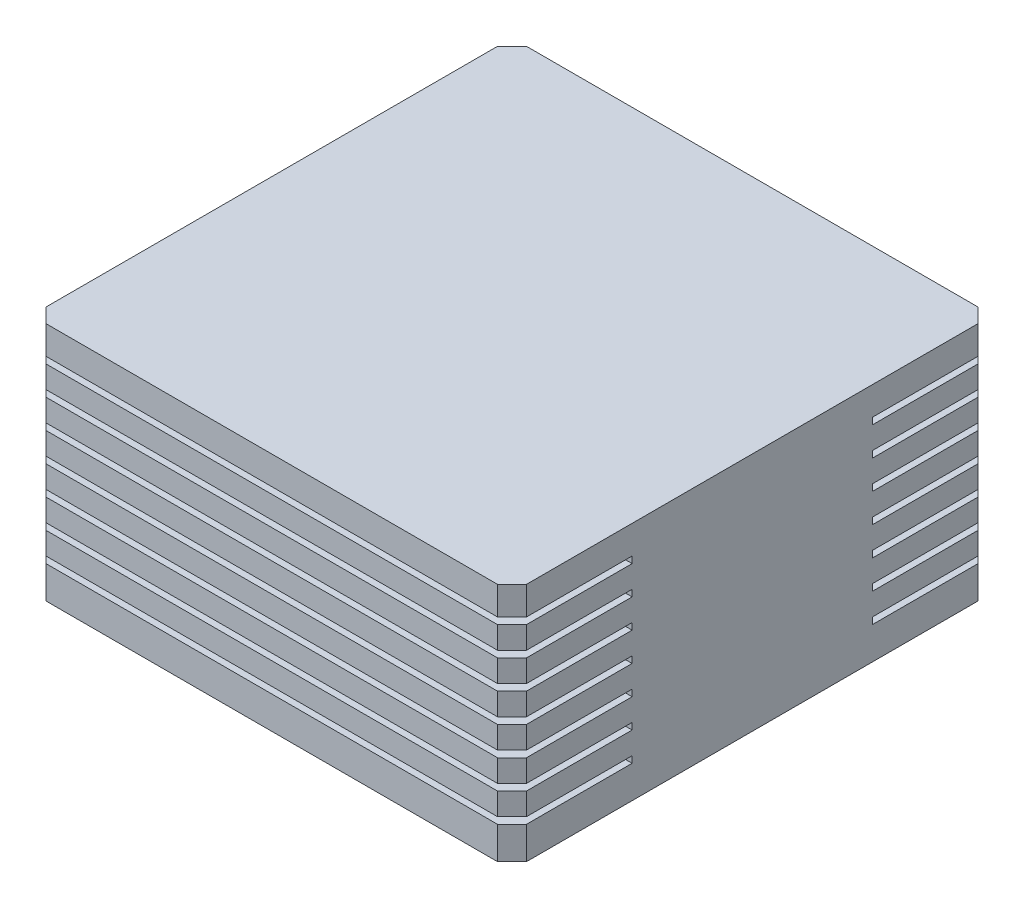
from build123d import *

# Parameters (mm, degrees)
SKETCH1_W           = 100
SKETCH1_H           = 100
BOSS_EXTRUDE1_DEPTH = 50
CHAMFER1_SIZE       = 3
SKETCH3_W           = 100
SKETCH3_H           = 1.369103339
CUT_EXTRUDE1_DEPTH  = 25
SKETCH4_W           = 72
SKETCH4_H           = 1.369103339
SKETCH4_W_2         = 3
SKETCH4_W_3         = 75
CUT_EXTRUDE2_DEPTH  = 25
SKETCH5_W           = 75
SKETCH5_H           = 1.369103339
CUT_EXTRUDE3_DEPTH  = 25


with BuildPart() as part:
    # Sketch1 → Boss-Extrude1 (new body)
    with BuildSketch(Plane(origin=(0, 0, 0), x_dir=(1, 0, 0), z_dir=(0, 1, 0))):
        with Locations((50, -50)):
            Rectangle(SKETCH1_W, SKETCH1_H)
    extrude(amount=BOSS_EXTRUDE1_DEPTH)

    # Chamfer1
    chamfer1_edges = [part.edges().sort_by_distance(p)[0] for p in [
        (0, 25, 0),
        (100, 25, 0),
        (100, 25, 100),
        (0, 25, 100),
    ]]
    chamfer(chamfer1_edges, length=CHAMFER1_SIZE)

    # Sketch3 → Cut-Extrude1 (cut)
    with BuildSketch(Plane.ZY):
        with Locations((50, 43.425849107)):
            Rectangle(SKETCH3_W, SKETCH3_H)
        with Locations((50, 37.425849107)):
            Rectangle(SKETCH3_W, SKETCH3_H)
        with Locations((50, 31.425849107)):
            Rectangle(SKETCH3_W, SKETCH3_H)
        with Locations((50, 25.425849107)):
            Rectangle(SKETCH3_W, SKETCH3_H)
        with Locations((50, 19.425849107)):
            Rectangle(SKETCH3_W, SKETCH3_H)
        with Locations((50, 13.425849107)):
            Rectangle(SKETCH3_W, SKETCH3_H)
        with Locations((50, 7.425849108)):
            Rectangle(SKETCH3_W, SKETCH3_H)
    extrude(amount=-CUT_EXTRUDE1_DEPTH, mode=Mode.SUBTRACT)

    # Sketch4 → Cut-Extrude2 (cut)
    with BuildSketch(Plane.XY.offset(100)):
        with Locations((61, 25.425849107)):
            Rectangle(SKETCH4_W, SKETCH4_H)
        with Locations((61, 19.425849107)):
            Rectangle(SKETCH4_W, SKETCH4_H)
        with Locations((61, 13.425849107)):
            Rectangle(SKETCH4_W, SKETCH4_H)
        with Locations((98.5, 25.425849107)):
            Rectangle(SKETCH4_W_2, SKETCH4_H)
        with Locations((98.5, 19.425849107)):
            Rectangle(SKETCH4_W_2, SKETCH4_H)
        with Locations((98.5, 13.425849107)):
            Rectangle(SKETCH4_W_2, SKETCH4_H)
        with Locations((62.5, 7.425849108)):
            Rectangle(SKETCH4_W_3, SKETCH4_H)
        with Locations((62.5, 31.425849107)):
            Rectangle(SKETCH4_W_3, SKETCH4_H)
        with Locations((62.5, 37.425849107)):
            Rectangle(SKETCH4_W_3, SKETCH4_H)
        with Locations((62.5, 43.425849107)):
            Rectangle(SKETCH4_W_3, SKETCH4_H)
    extrude(amount=-CUT_EXTRUDE2_DEPTH, mode=Mode.SUBTRACT)

    # Sketch5 → Cut-Extrude3 (cut)
    with BuildSketch(Plane(origin=(0, 0, 0), x_dir=(-1, 0, 0), z_dir=(0, 0, -1))):
        with Locations((-62.5, 43.425849107)):
            Rectangle(SKETCH5_W, SKETCH5_H)
        with Locations((-62.5, 37.425849107)):
            Rectangle(SKETCH5_W, SKETCH5_H)
        with Locations((-62.5, 31.425849107)):
            Rectangle(SKETCH5_W, SKETCH5_H)
        with Locations((-62.5, 25.425849107)):
            Rectangle(SKETCH5_W, SKETCH5_H)
        with Locations((-62.5, 19.425849107)):
            Rectangle(SKETCH5_W, SKETCH5_H)
        with Locations((-62.5, 13.425849107)):
            Rectangle(SKETCH5_W, SKETCH5_H)
        with Locations((-62.5, 7.425849108)):
            Rectangle(SKETCH5_W, SKETCH5_H)
    extrude(amount=-CUT_EXTRUDE3_DEPTH, mode=Mode.SUBTRACT)


solid = part.part
